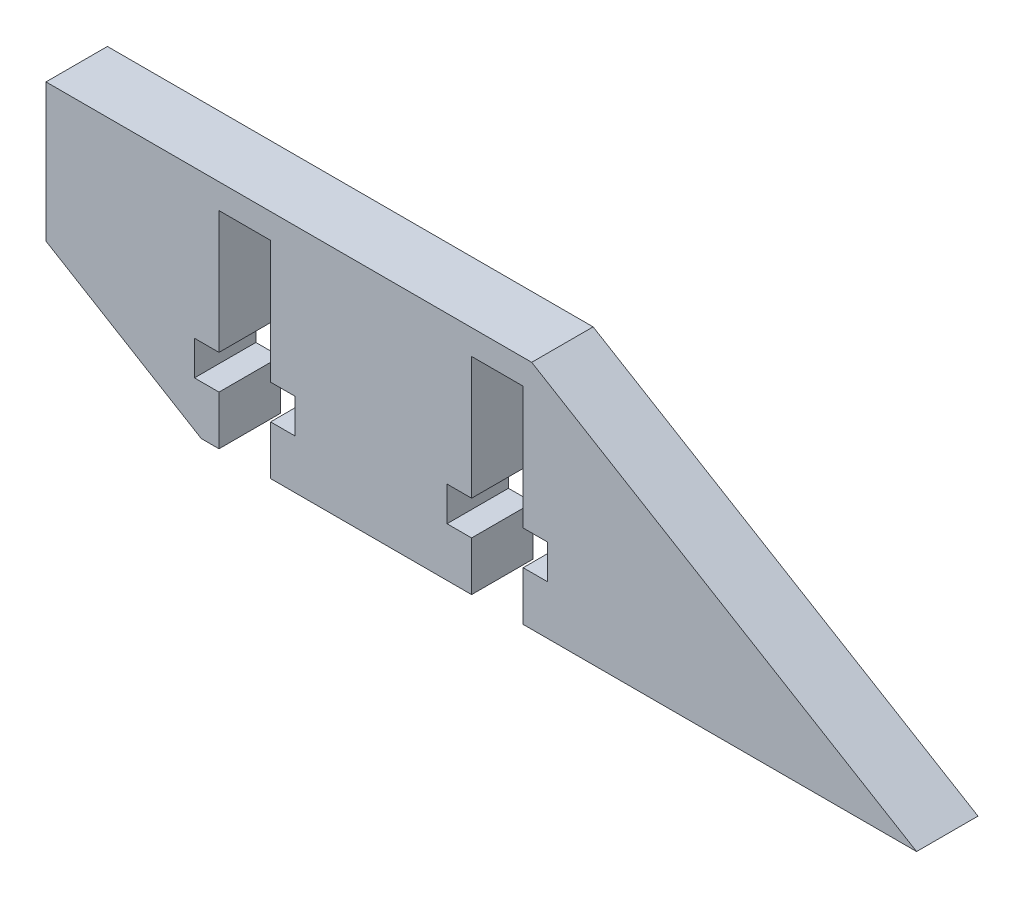
from build123d import *

# Parameters (mm, degrees)
BOSS_EXTRUDE1_DEPTH     = 5
CUT_EXTRUDE1_DEPTH      = 1
CUT_EXTRUDE1_DEPTH_BACK = 6


with BuildPart() as part:
    # Sketch3 → Boss-Extrude1 (new body)
    with BuildSketch(Plane.XY.offset(-218.000000001)):
        Polygon((-282.039404117, 408.696835159), (-340.287524909, 408.696835159), (-352.932442284, 416.294668041), (-352.932442284, 427.528407952), (-313.380404337, 427.528407952), align=None)
    extrude(amount=-BOSS_EXTRUDE1_DEPTH)

    # Sketch4 → Cut-Extrude1 (cut, two sides)
    with BuildSketch(Plane(origin=(0, 0, -223.000000001), x_dir=(-1, 0, 0), z_dir=(0, 0, -1))) as cut_extrude1_sk:
        Polygon((318.275750374, 408.696835159), (314.075750374, 408.696835159), (314.075750374, 412.696835159), (312.075750374, 412.696835159), (312.075750374, 415.496835159), (314.075750374, 415.496835159), (314.075750374, 425.496835159), (318.275750374, 425.496835159), (318.275750374, 415.496835159), (320.275750374, 415.496835159), (320.275750374, 412.696835159), (318.275750374, 412.696835159), align=None)
        Polygon((338.843972624, 412.696835159), (340.843972624, 412.696835159), (340.843972624, 415.496835159), (338.843972624, 415.496835159), (338.843972624, 425.496835159), (334.643972624, 425.496835159), (334.643972624, 415.496835159), (332.643972624, 415.496835159), (332.643972624, 412.696835159), (334.643972624, 412.696835159), (334.643972624, 408.696835159), (338.843972624, 408.696835159), align=None)
    extrude(amount=CUT_EXTRUDE1_DEPTH, mode=Mode.SUBTRACT)
    extrude(cut_extrude1_sk.sketch, amount=-CUT_EXTRUDE1_DEPTH_BACK, mode=Mode.SUBTRACT)


solid = part.part
